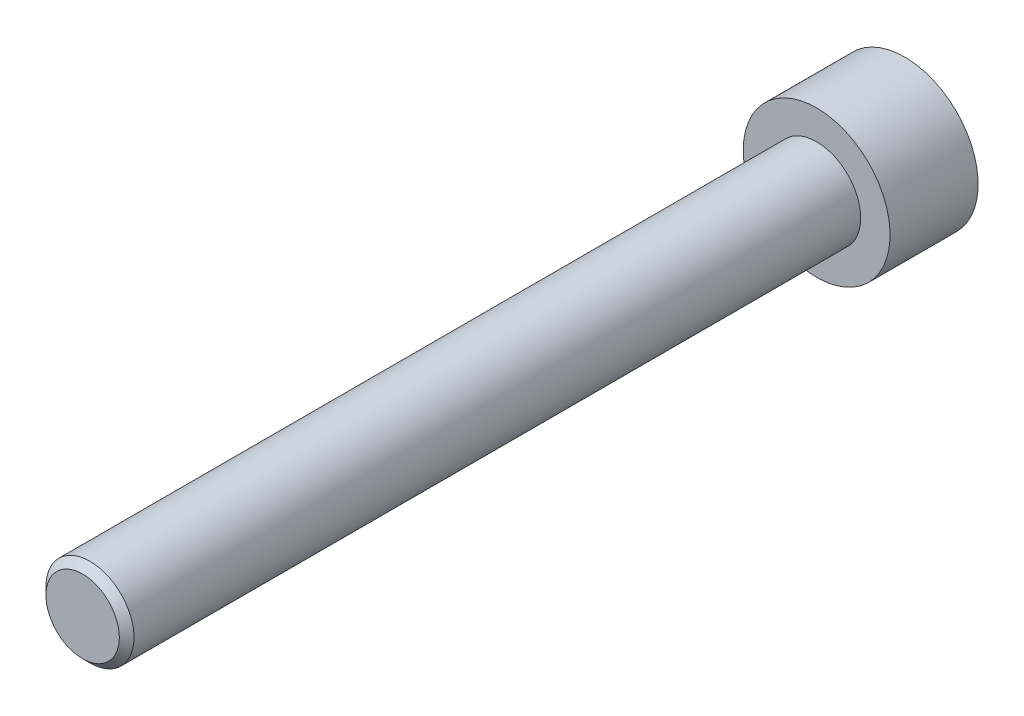
from build123d import *

# Parameters (mm, degrees)
ESTRUSIONE_ESTRUSIONE1_START      = -11.2
SCHIZZO1_R                        = 3
ESTRUSIONE_ESTRUSIONE1_DEPTH      = 12
ESTRUSIONE_ESTRUSIONE1_DEPTH_BACK = 44
SMUSSO1_SIZE                      = 0.5
SCHIZZO4_R                        = 5
ESTRUSIONE_ESTRUSIONE2_DEPTH      = 6
TAGLIO_ESTRUSIONE1_DEPTH          = 2


with BuildPart() as part:
    # Schizzo1 → Estrusione-Estrusione1 (new body, two sides)
    with BuildSketch(Plane.XY.offset(ESTRUSIONE_ESTRUSIONE1_START)) as estrusione_estrusione1_sk:
        Circle(SCHIZZO1_R)
    extrude(amount=ESTRUSIONE_ESTRUSIONE1_DEPTH)
    extrude(estrusione_estrusione1_sk.sketch, amount=-ESTRUSIONE_ESTRUSIONE1_DEPTH_BACK)

    # Smusso1
    smusso1_edges = [part.edges().sort_by_distance(p)[0] for p in [
        (-3, 0, 0.8),
        (-3, 0, -55.2),
    ]]
    chamfer(smusso1_edges, length=SMUSSO1_SIZE)

    # Schizzo4 → Estrusione-Estrusione2 (add)
    with BuildSketch(Plane(origin=(0, 0, -55.2), x_dir=(-1, 0, 0), z_dir=(0, 0, -1))):
        Circle(SCHIZZO4_R)
    extrude(amount=-ESTRUSIONE_ESTRUSIONE2_DEPTH)

    # Schizzo6 → Taglio-Estrusione1 (cut)
    with BuildSketch(Plane(origin=(0, 0, -55.2), x_dir=(-1, 0, 0), z_dir=(0, 0, -1))):
        Polygon((1.5, 3), (-1.5, 3), (-3.232050808, 0), (-1.5, -3), (1.5, -3), (3.232050808, 0), align=None)
    extrude(amount=-TAGLIO_ESTRUSIONE1_DEPTH, mode=Mode.SUBTRACT)


solid = part.part
